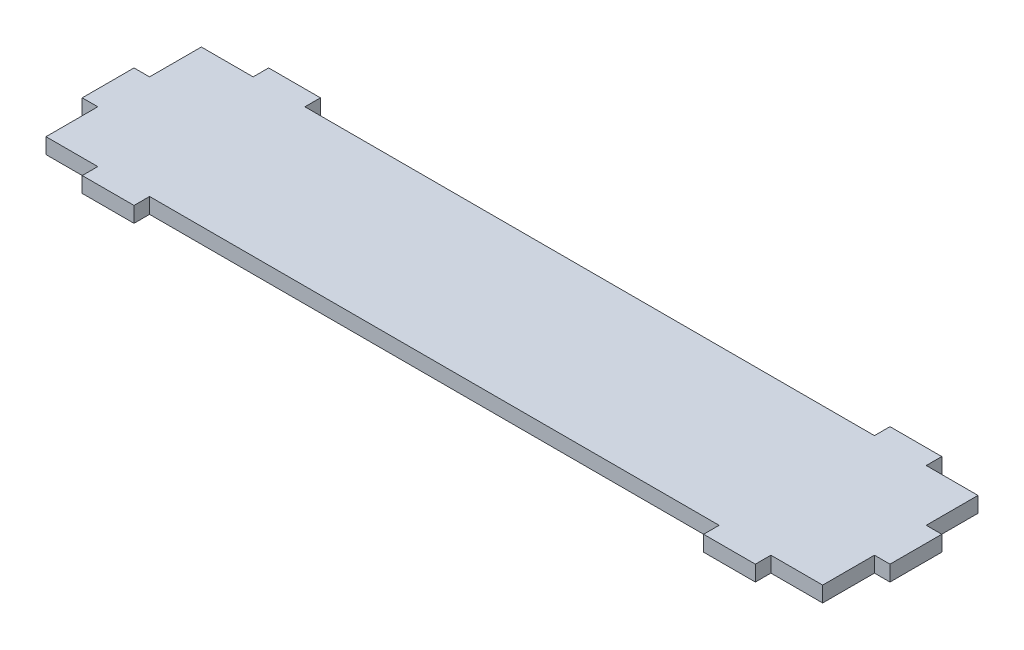
from build123d import *

# Parameters (mm, degrees)
BOSS_EXTRU_1_DEPTH = 3


with BuildPart() as part:
    # Esquisse1 → Boss.-Extru.1 (new body)
    with BuildSketch(Plane(origin=(0, 0, 0), x_dir=(1, 0, 0), z_dir=(0, 1, 0))):
        Polygon((91.843823667, 25.907471498), (91.843823667, 28.907471498), (101.843823667, 28.907471498), (101.843823667, 25.907471498), (111.843823667, 25.907471498), (111.843823667, 15.907471498), (114.843823667, 15.907471498), (114.843823667, 5.907471498), (111.843823667, 5.907471498), (111.843823667, -4.092528502), (101.843823667, -4.092528502), (101.843823667, -7.092528502), (91.843823667, -7.092528502), (91.843823667, -4.092528502), (-18.156176333, -4.092528502), (-18.156176333, -7.092528502), (-28.156176333, -7.092528502), (-28.156176333, -4.092528502), (-38.156176333, -4.092528502), (-38.156176333, 5.907471498), (-41.156176333, 5.907471498), (-41.156176333, 15.907471498), (-38.156176333, 15.907471498), (-38.156176333, 25.907471498), (-28.156176333, 25.907471498), (-28.156176333, 28.907471498), (-18.156176333, 28.907471498), (-18.156176333, 25.907471498), align=None)
    extrude(amount=BOSS_EXTRU_1_DEPTH)


solid = part.part
